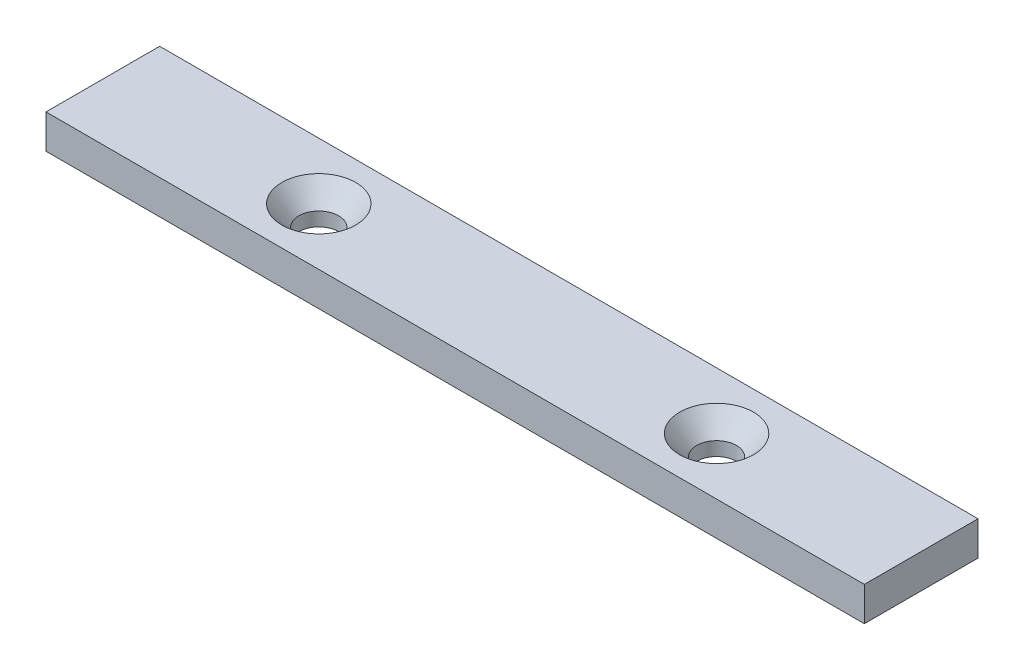
from build123d import *

# Parameters (mm, degrees)
SKETCH1_W                                      = 144
SKETCH1_H                                      = 20
BOSS_EXTRUDE1_DEPTH                            = 6
CSK_FOR_M5_FLAT_HEAD_MACHINE_SCREW1_AT_2_COUNT = 2
CSK_FOR_M5_FLAT_HEAD_MACHINE_SCREW1_AT_2_PITCH = 70


with BuildPart() as part:
    # Sketch1 → Boss-Extrude1 (new body)
    with BuildSketch(Plane(origin=(0, 0, 0), x_dir=(1, 0, 0), z_dir=(0, 1, 0))):
        with Locations((72, 10)):
            Rectangle(SKETCH1_W, SKETCH1_H)
    extrude(amount=BOSS_EXTRUDE1_DEPTH)

    # Sketch2 → CSK for M5 Flat Head Machine Screw1 (revolve, cut)
    with BuildSketch(Plane(origin=(38, 6, -10), x_dir=(0, 0, 1), z_dir=(1, 0, 0))):
        Polygon((0, 0), (0, 6), (3.5, 6), (3.5, 3.575260778), (6.5, 0), align=None)
    csk_for_m5_flat_head_machine_screw1 = revolve(axis=Axis((38, 12.35, -10), (0, -1, 0)), mode=Mode.SUBTRACT)

    # CSK for M5 Flat Head Machine Screw1 at 2: CSK for M5 Flat Head Machine Screw1 ×2
    with Locations(*[(i * CSK_FOR_M5_FLAT_HEAD_MACHINE_SCREW1_AT_2_PITCH, 0, 0) for i in range(1, CSK_FOR_M5_FLAT_HEAD_MACHINE_SCREW1_AT_2_COUNT)]):
        add(csk_for_m5_flat_head_machine_screw1, mode=Mode.SUBTRACT)


solid = part.part
